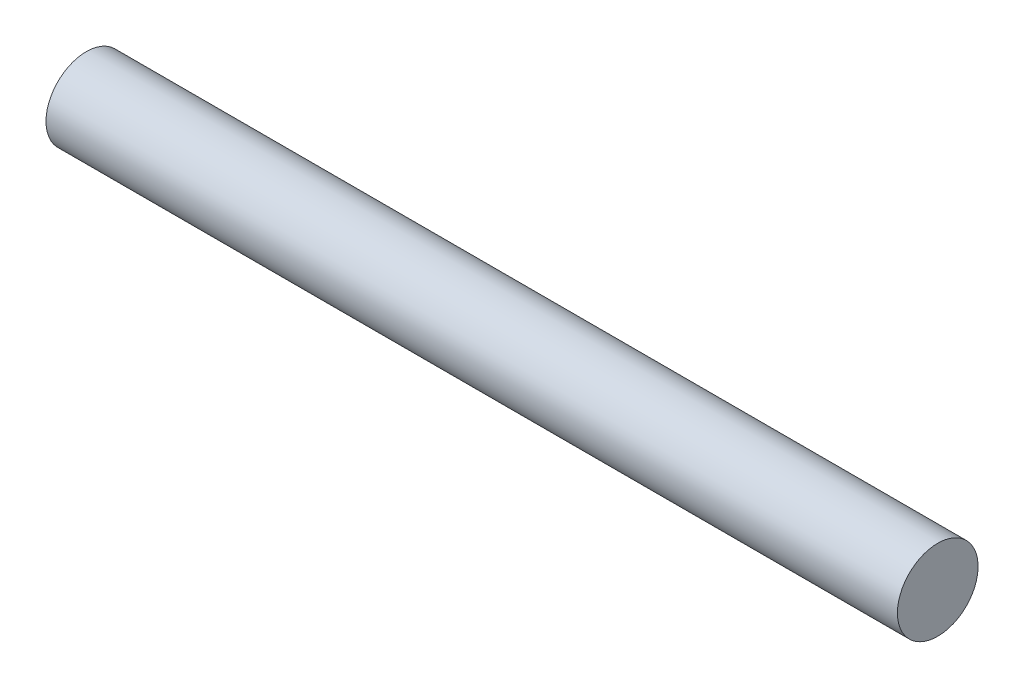
from build123d import *

# Parameters (mm, degrees)
IZIM1_W = 190.04876731
IZIM1_H = 9


with BuildPart() as part:
    # Çizim1 → Döndür1 (revolve)
    with BuildSketch(Plane.XY):
        with Locations((-74.611935993, 456.499785752)):
            Rectangle(IZIM1_W, IZIM1_H)
    revolve(axis=Axis((-169.636319648, 451.999785752, 0), (1, 0, 0)))


solid = part.part
